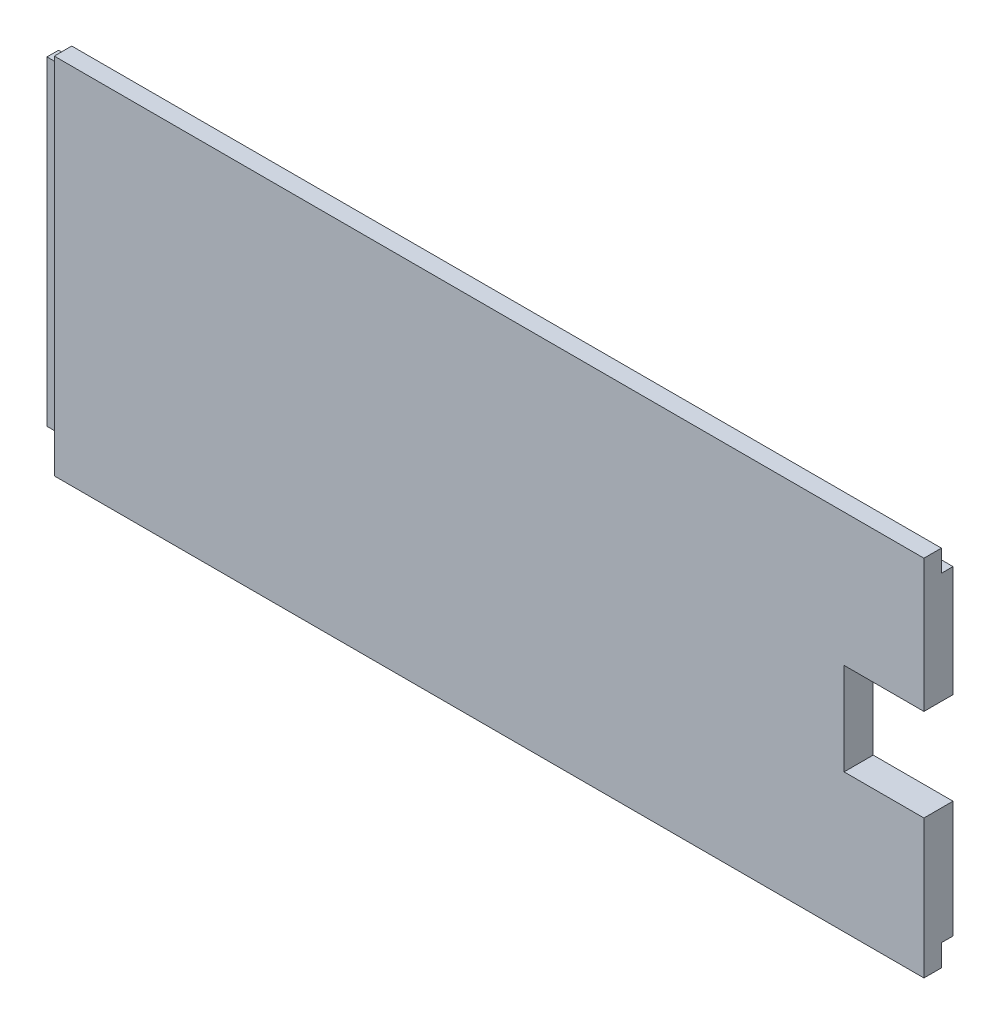
from build123d import *

# Parameters (mm, degrees)
SKETCH3_W           = 156.21
SKETCH3_H           = 55.88
BOSS_EXTRUDE2_DEPTH = 2.032
SKETCH4_W           = 151.888767811
SKETCH4_H           = 63.5
BOSS_EXTRUDE3_DEPTH = 3.048
SKETCH5_W           = 13.94179759
SKETCH5_H           = 16.111517863
CUT_EXTRUDE1_DEPTH  = 6.08


with BuildPart() as part:
    # Sketch3 → Boss-Extrude2 (new body)
    with BuildSketch(Plane.XY):
        with Locations((75.809845761, 22.583067422)):
            Rectangle(SKETCH3_W, SKETCH3_H)
    extrude(amount=BOSS_EXTRUDE2_DEPTH)

    # Sketch4 → Boss-Extrude3 (add)
    with BuildSketch(Plane.XY.offset(2.032)):
        with Locations((77.970461856, 22.583067422)):
            Rectangle(SKETCH4_W, SKETCH4_H)
    extrude(amount=BOSS_EXTRUDE3_DEPTH)

    # Sketch5 → Cut-Extrude1 (cut, through all)
    with BuildSketch(Plane.XY.offset(5.08)):
        with Locations((146.943946966, 23.09296993)):
            Rectangle(SKETCH5_W, SKETCH5_H)
    extrude(amount=-CUT_EXTRUDE1_DEPTH, mode=Mode.SUBTRACT)


solid = part.part
